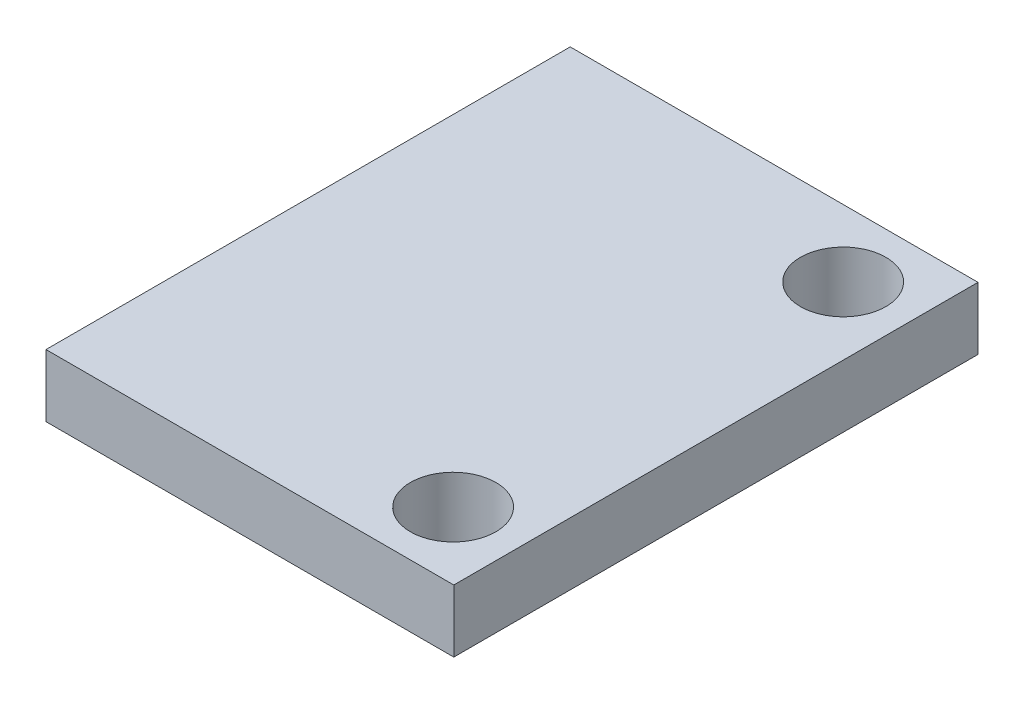
from build123d import *

# Parameters (mm, degrees)
SKETCH1_W           = 15.748
SKETCH1_H           = 20.2438
SKETCH1_R           = 1.651
BOSS_EXTRUDE1_DEPTH = 2.413


with BuildPart() as part:
    # Sketch1 → Boss-Extrude1 (new body)
    with BuildSketch(Plane(origin=(0, 0, 0), x_dir=(1, 0, 0), z_dir=(0, 1, 0))):
        Rectangle(SKETCH1_W, SKETCH1_H)
        with Locations((5.2578, 7.5311)):
            Circle(SKETCH1_R, mode=Mode.SUBTRACT)
        with Locations((5.2578, -7.5311)):
            Circle(SKETCH1_R, mode=Mode.SUBTRACT)
    extrude(amount=BOSS_EXTRUDE1_DEPTH)


solid = part.part
